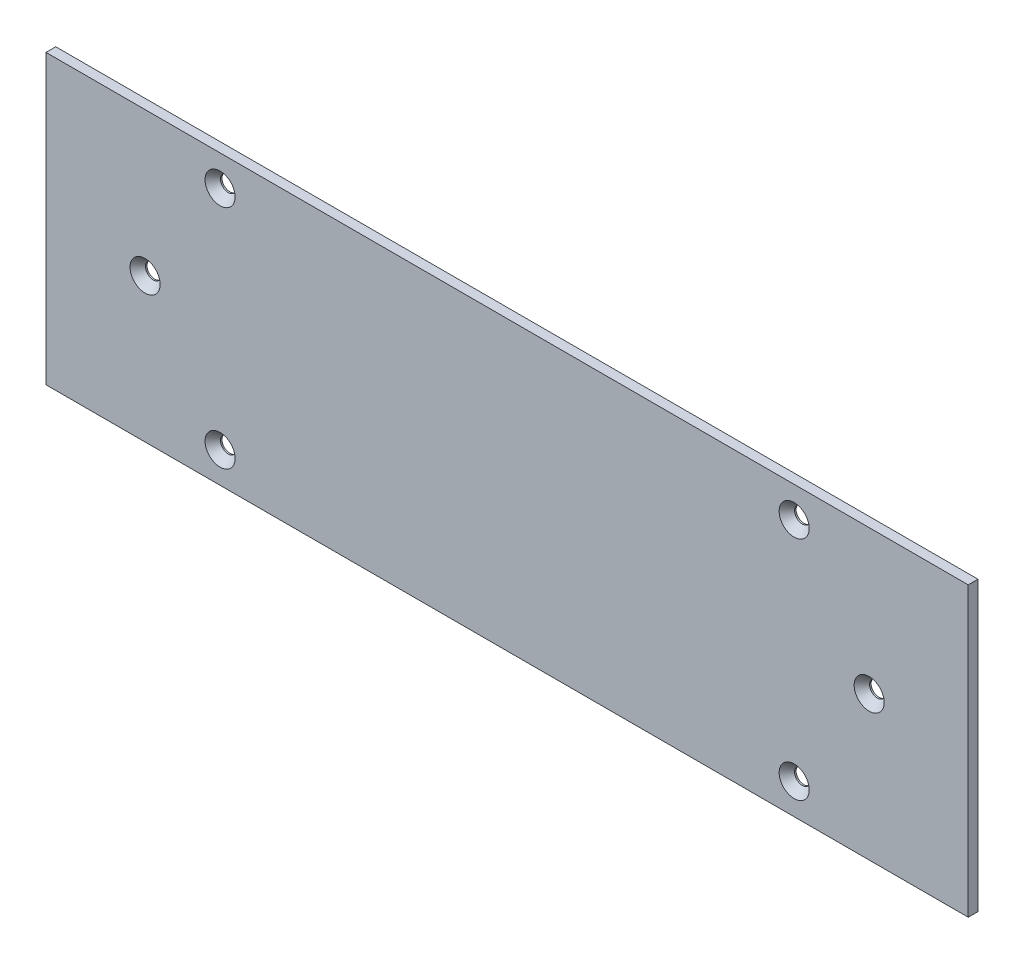
from build123d import *

# Parameters (mm, degrees)
SKETCH1_W                                       = 299.999999694
SKETCH1_H                                       = 93.649999898
BOSS_EXTRUDE1_DEPTH                             = 3.175
CSK_FOR_10_FLAT_HEAD_MACHINE_SCREW1_D           = 5.1054
CSK_FOR_10_FLAT_HEAD_MACHINE_SCREW1_DEPTH       = 4.826
CSK_FOR_10_FLAT_HEAD_MACHINE_SCREW1_CSINK_D     = 9.779
CSK_FOR_10_FLAT_HEAD_MACHINE_SCREW1_CSINK_ANGLE = 82
CSK_FOR_10_FLAT_HEAD_MACHINE_SCREW1_TIP         = 1.533816902
CSK_FOR_10_FLAT_HEAD_MACHINE_SCREW2_D           = 5.1054
CSK_FOR_10_FLAT_HEAD_MACHINE_SCREW2_DEPTH       = 4.826
CSK_FOR_10_FLAT_HEAD_MACHINE_SCREW2_CSINK_D     = 9.779
CSK_FOR_10_FLAT_HEAD_MACHINE_SCREW2_CSINK_ANGLE = 82
CSK_FOR_10_FLAT_HEAD_MACHINE_SCREW2_TIP         = 1.533816902


with BuildPart() as part:
    # Sketch1 → Boss-Extrude1 (new body)
    with BuildSketch(Plane.XY):
        Rectangle(SKETCH1_W, SKETCH1_H)
    extrude(amount=BOSS_EXTRUDE1_DEPTH)

    # CSK for #10 Flat Head Machine Screw1
    with Locations(Plane.XY.offset(3.175)):
        with Locations((-93.374999847, 36.824999949), (93.374999847, 36.824999949), (93.374999847, -36.824999949), (-93.374999847, -36.824999949)):
            CounterSinkHole(CSK_FOR_10_FLAT_HEAD_MACHINE_SCREW1_D / 2, CSK_FOR_10_FLAT_HEAD_MACHINE_SCREW1_CSINK_D / 2, depth=CSK_FOR_10_FLAT_HEAD_MACHINE_SCREW1_DEPTH, counter_sink_angle=CSK_FOR_10_FLAT_HEAD_MACHINE_SCREW1_CSINK_ANGLE)
            with Locations((0, 0, -(CSK_FOR_10_FLAT_HEAD_MACHINE_SCREW1_DEPTH + CSK_FOR_10_FLAT_HEAD_MACHINE_SCREW1_TIP / 2))):  # 118° drill point
                Cone(0, CSK_FOR_10_FLAT_HEAD_MACHINE_SCREW1_D / 2, CSK_FOR_10_FLAT_HEAD_MACHINE_SCREW1_TIP, mode=Mode.SUBTRACT)

    # CSK for #10 Flat Head Machine Screw2
    with Locations(Plane.XY.offset(3.175)):
        with Locations((-117.774999847, 0), (117.774999847, 0)):
            CounterSinkHole(CSK_FOR_10_FLAT_HEAD_MACHINE_SCREW2_D / 2, CSK_FOR_10_FLAT_HEAD_MACHINE_SCREW2_CSINK_D / 2, depth=CSK_FOR_10_FLAT_HEAD_MACHINE_SCREW2_DEPTH, counter_sink_angle=CSK_FOR_10_FLAT_HEAD_MACHINE_SCREW2_CSINK_ANGLE)
            with Locations((0, 0, -(CSK_FOR_10_FLAT_HEAD_MACHINE_SCREW2_DEPTH + CSK_FOR_10_FLAT_HEAD_MACHINE_SCREW2_TIP / 2))):  # 118° drill point
                Cone(0, CSK_FOR_10_FLAT_HEAD_MACHINE_SCREW2_D / 2, CSK_FOR_10_FLAT_HEAD_MACHINE_SCREW2_TIP, mode=Mode.SUBTRACT)


solid = part.part
